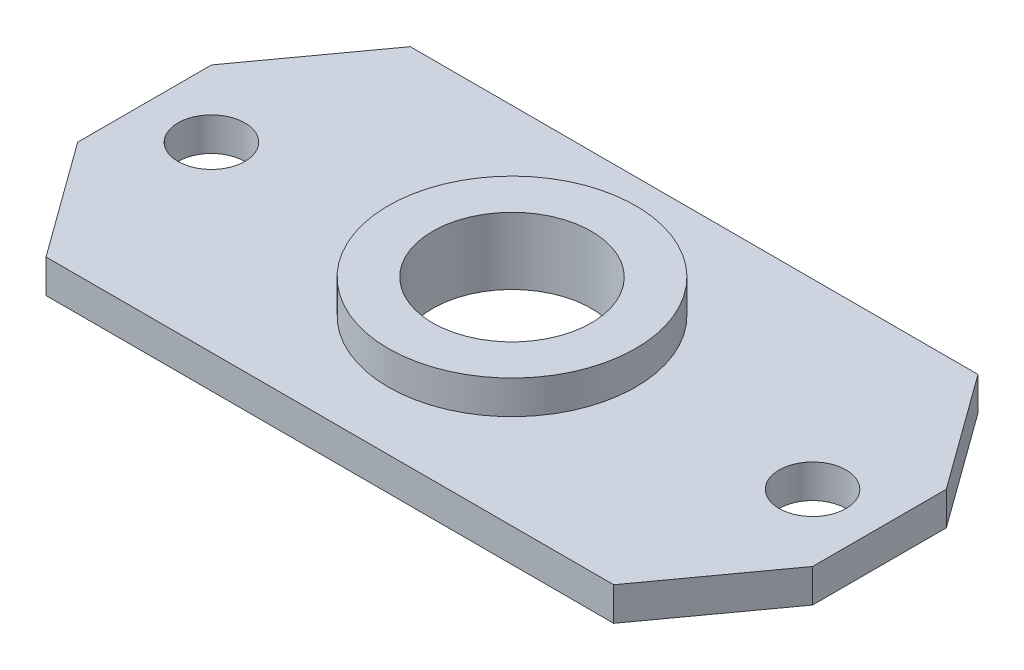
from build123d import *

# Parameters (mm, degrees)
SKETCH1_R           = 2
BOSS_EXTRUDE1_DEPTH = 2
SKETCH2_R           = 7.4
BOSS_EXTRUDE2_DEPTH = 2
SKETCH3_R           = 4.75
CUT_EXTRUDE1_DEPTH  = 5


with BuildPart() as part:
    # Sketch1 → Boss-Extrude1 (new body)
    with BuildSketch(Plane(origin=(0, 0, 0), x_dir=(1, 0, 0), z_dir=(0, 1, 0))):
        Polygon((0, 0), (33.96, 0), (38.96, 6.895), (38.96, 14.895), (33.96, 21.79), (0, 21.79), (-5, 14.895), (-5, 6.895), align=None)
        with Locations((-1, 10.895)):
            Circle(SKETCH1_R, mode=Mode.SUBTRACT)
        with Locations((34.96, 10.895)):
            Circle(SKETCH1_R, mode=Mode.SUBTRACT)
    extrude(amount=BOSS_EXTRUDE1_DEPTH)

    # Sketch2 → Boss-Extrude2 (add)
    with BuildSketch(Plane(origin=(0, 2, 0), x_dir=(1, 0, 0), z_dir=(0, 1, 0))):
        with Locations((16.98, 10.895)):
            Circle(SKETCH2_R)
    extrude(amount=BOSS_EXTRUDE2_DEPTH)

    # Sketch3 → Cut-Extrude1 (cut, through all)
    with BuildSketch(Plane(origin=(0, 4, 0), x_dir=(1, 0, 0), z_dir=(0, 1, 0))):
        with Locations((16.98, 10.895)):
            Circle(SKETCH3_R)
    extrude(amount=-CUT_EXTRUDE1_DEPTH, mode=Mode.SUBTRACT)


solid = part.part
